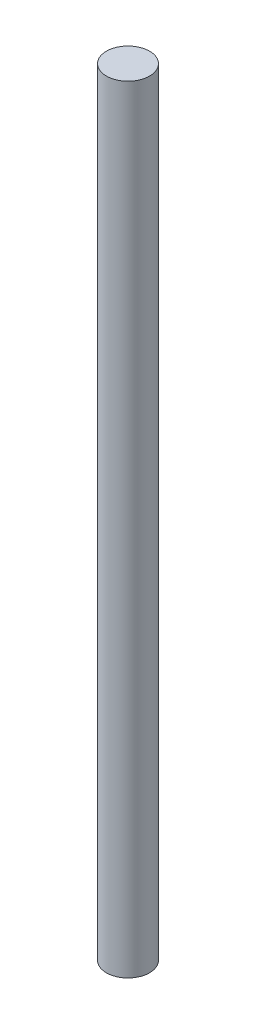
from build123d import *

# Parameters (mm, degrees)
SKETCH1_R           = 12.7
BOSS_EXTRUDE1_DEPTH = 457.2


with BuildPart() as part:
    # Sketch1 → Boss-Extrude1 (new body)
    with BuildSketch(Plane(origin=(0, 0, 0), x_dir=(1, 0, 0), z_dir=(0, 1, 0))):
        Circle(SKETCH1_R)
    extrude(amount=BOSS_EXTRUDE1_DEPTH)


solid = part.part
